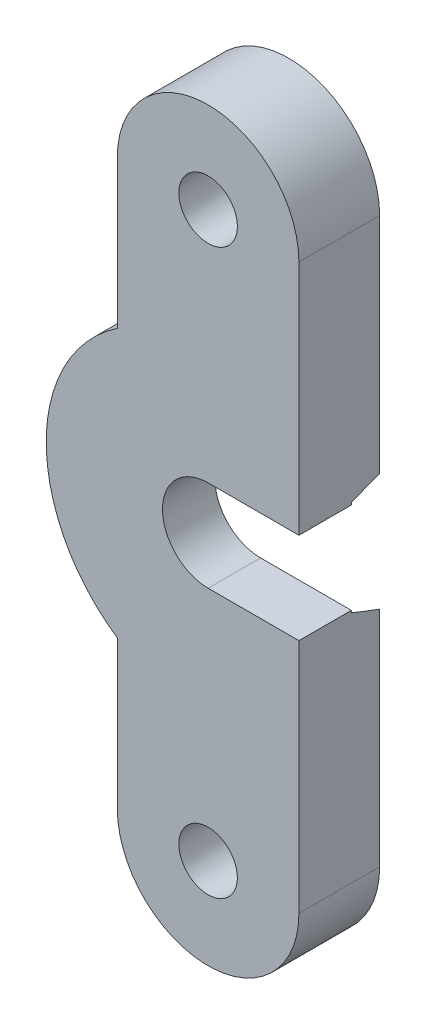
from build123d import *

# Parameters (mm, degrees)
SKETCH1_R           = 1.45
BOSS_EXTRUDE1_DEPTH = 4
SKETCH2_R           = 5.35614303
CUT_EXTRUDE1_DEPTH  = 1.4
CUT_EXTRUDE1_TAPER  = 11
CUT_EXTRUDE2_DEPTH  = 5.5


with BuildPart() as part:
    # Sketch1 → Boss-Extrude1 (new body)
    with BuildSketch(Plane.XY):
        with BuildLine():
            Line((-19, 6.631961257), (-19, 13.975))
            ThreePointArc((-19, 13.975), (-14.5, 18.475), (-10, 13.975))
            Line((-10, 13.975), (-10, -13.975))
            ThreePointArc((-10, -13.975), (-14.5, -18.475), (-19, -13.975))
            Line((-19, -13.975), (-19, -6.651961257))
            ThreePointArc((-19, -6.651961257), (-22.522820535, -0.01), (-19, 6.631961257))
        make_face()
        with Locations((-14.5, -13.975)):
            Circle(SKETCH1_R, mode=Mode.SUBTRACT)
        with Locations((-14.5, 13.975)):
            Circle(SKETCH1_R, mode=Mode.SUBTRACT)
    extrude(amount=BOSS_EXTRUDE1_DEPTH)

    # Sketch2 → Cut-Extrude1 (cut)
    with BuildSketch(Plane(origin=(0, 0, 0), x_dir=(-1, 0, 0), z_dir=(0, 0, -1))):
        with Locations((14.5, -0.01)):
            Circle(SKETCH2_R)
    extrude(amount=-CUT_EXTRUDE1_DEPTH, taper=CUT_EXTRUDE1_TAPER, mode=Mode.SUBTRACT)

    # Sketch3 → Cut-Extrude2 (cut)
    with BuildSketch(Plane.XY.offset(4)):
        with BuildLine():
            Line((-14.5, -2.270184411), (-10, -2.270184411))
            Line((-10, -2.270184411), (-10, 2.250184411))
            Line((-10, 2.250184411), (-14.5, 2.250184411))
            ThreePointArc((-14.5, 2.250184411), (-16.760184411, -0.01), (-14.5, -2.270184411))
        make_face()
    extrude(amount=-CUT_EXTRUDE2_DEPTH, mode=Mode.SUBTRACT)


solid = part.part
